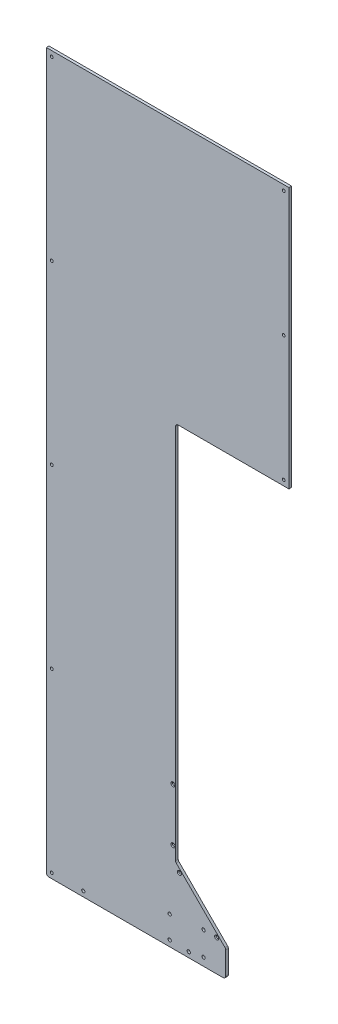
from build123d import *

# Parameters (mm, degrees)
SKETCH2_W                                          = 584.2
SKETCH2_H                                          = 1727.2
BOSS_EXTRUDE1_DEPTH                                = 6.35
CUT_EXTRUDE1_DEPTH                                 = 7.35
H_0_266_DIAMETER_HOLE1_D                           = 6.7564
FILLET1_R                                          = 6.35
SKETCH7_R                                          = 3.96875
CUT_EXTRUDE2_DEPTH                                 = 12.7
CSK_FOR_10_FLAT_HEAD_MACHINE_SCREW_100_D           = 5.6134
CSK_FOR_10_FLAT_HEAD_MACHINE_SCREW_100_DEPTH       = 6.35
CSK_FOR_10_FLAT_HEAD_MACHINE_SCREW_100_CSINK_D     = 9.779
CSK_FOR_10_FLAT_HEAD_MACHINE_SCREW_100_CSINK_ANGLE = 100
SKETCH13_R                                         = 3.937
CUT_EXTRUDE3_DEPTH                                 = 7.35
F_5_16_0_3125_DIAMETER_HOLE1_D                     = 7.9375


with BuildPart() as part:
    # Sketch2 → Boss-Extrude1 (new body)
    with BuildSketch(Plane.XY):
        with Locations((292.1, 863.6)):
            Rectangle(SKETCH2_W, SKETCH2_H)
    extrude(amount=BOSS_EXTRUDE1_DEPTH)

    # Sketch3 → Cut-Extrude1 (cut, through all)
    with BuildSketch(Plane.XY.offset(6.35)):
        Polygon((584.2, 1098.55), (311.15, 1098.55), (311.15, 184.15), (431.8, 63.5), (431.8, 0), (584.2, 0), align=None)
    extrude(amount=-CUT_EXTRUDE1_DEPTH, mode=Mode.SUBTRACT)

    # H (0.266) Diameter Hole1 (through all)
    with Locations(Plane.XY.offset(6.35)):
        with Locations((12.7, 1714.5), (12.7, 1289.05), (12.7, 863.6), (12.7, 438.15), (12.7, 12.7), (571.5, 1111.25), (571.5, 1412.875), (571.5, 1714.5)):
            Hole(H_0_266_DIAMETER_HOLE1_D / 2)

    # Fillet1
    fillet1_edges = [part.edges().sort_by_distance(p)[0] for p in [
        (431.8, 0, 3.175),
        (431.8, 63.5, 3.175),
        (311.15, 184.15, 3.175),
        (311.15, 1098.55, 3.175),
        (0, 0, 3.175),
    ]]
    fillet(fillet1_edges, radius=FILLET1_R)

    # Sketch7 → Cut-Extrude2 (cut)
    with BuildSketch(Plane.XY.offset(6.35)):
        with Locations((88.9, 12.7)):
            Circle(SKETCH7_R)
        with Locations((342.9, 12.7)):
            Circle(SKETCH7_R)
    extrude(amount=-CUT_EXTRUDE2_DEPTH, mode=Mode.SUBTRACT)

    # CSK for #10 Flat Head Machine Screw (100)1
    with Locations(Plane.XY.offset(6.35)):
        with Locations((304.8, 342.9), (304.8, 215.9), (320.317182668, 166.002561211), (410.119743879, 76.2)):
            CounterSinkHole(CSK_FOR_10_FLAT_HEAD_MACHINE_SCREW_100_D / 2, CSK_FOR_10_FLAT_HEAD_MACHINE_SCREW_100_CSINK_D / 2, depth=CSK_FOR_10_FLAT_HEAD_MACHINE_SCREW_100_DEPTH, counter_sink_angle=CSK_FOR_10_FLAT_HEAD_MACHINE_SCREW_100_CSINK_ANGLE)

    # Sketch13 → Cut-Extrude3 (cut, through all)
    with BuildSketch(Plane(origin=(0, 0, 0), x_dir=(-1, 0, 0), z_dir=(0, 0, -1))):
        with Locations((-378.46762, 76.2)):
            Circle(SKETCH13_R)
        with Locations((-378.46762, 19.05)):
            Circle(SKETCH13_R)
    extrude(amount=-CUT_EXTRUDE3_DEPTH, mode=Mode.SUBTRACT)

    # 5/16 (0.3125) Diameter Hole1 (through all)
    with Locations(Plane.XY.offset(6.35)):
        with Locations((296.8625, 14.2875), (296.8625, 68.2625)):
            Hole(F_5_16_0_3125_DIAMETER_HOLE1_D / 2)


solid = part.part
